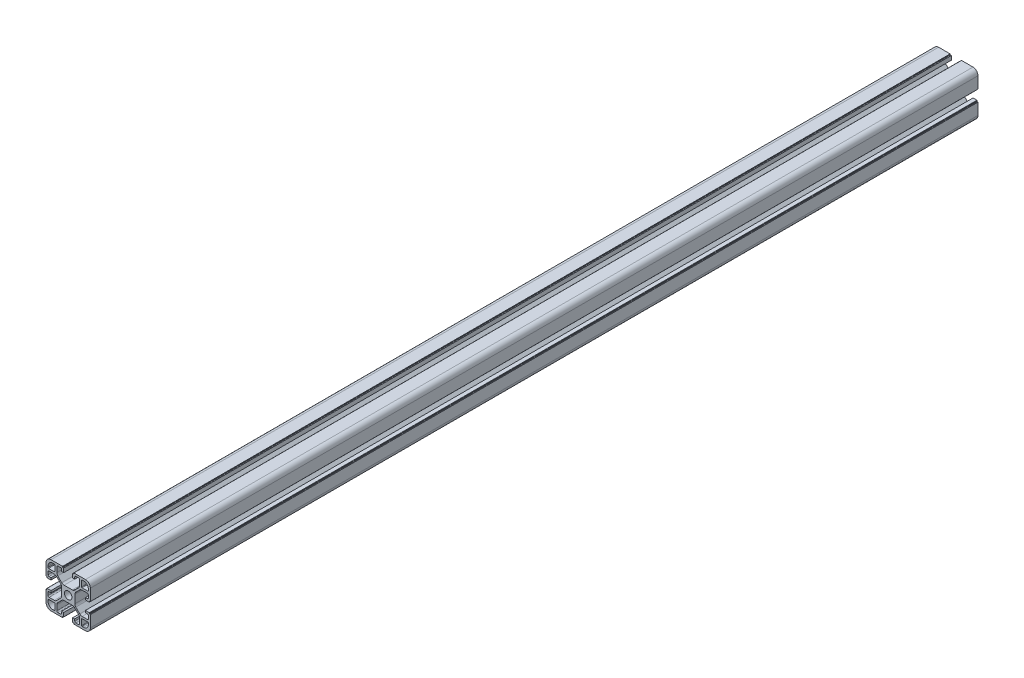
from build123d import *

# Parameters (mm, degrees)
BOSS_EXTRUDE1_DEPTH = 800


with BuildPart() as part:
    # Sketch2 → Boss-Extrude1 (new body)
    with BuildSketch(Plane.XY):
        with BuildLine():
            Line((84.170223908, 31.720417041), (84.170223908, 42.120417041))
            Line((84.170223908, 42.120417041), (83.570223908, 42.120417041))
            ThreePointArc((83.570223908, 42.120417041), (83.428802552, 42.178995685), (83.370223908, 42.320417041))
            Line((83.370223908, 42.320417041), (83.370223908, 42.920417041))
            ThreePointArc((83.370223908, 42.920417041), (83.311645264, 43.061838398), (83.170223908, 43.120417041))
            Line((83.170223908, 43.120417041), (79.670223908, 43.120417041))
            Line((79.670223908, 43.120417041), (79.670223908, 41.320417041))
            Line((79.670223908, 41.320417041), (81.370223908, 41.320417041))
            ThreePointArc((81.370223908, 41.320417041), (82.077330689, 41.027523823), (82.370223908, 40.320417041))
            Line((82.370223908, 40.320417041), (82.370223908, 37.970417041))
            ThreePointArc((82.370223908, 37.970417041), (82.077330689, 37.26331026), (81.370223908, 36.970417041))
            Line((81.370223908, 36.970417041), (76.723524767, 36.970417041))
            ThreePointArc((76.723524767, 36.970417041), (75.57547447, 37.198778444), (74.602204423, 37.849096698))
            Line((74.602204423, 37.849096698), (71.048903564, 41.402397557))
            ThreePointArc((71.048903564, 41.402397557), (70.39858531, 42.375667603), (70.170223908, 43.5237179))
            Line((70.170223908, 43.5237179), (70.170223908, 50.917116183))
            ThreePointArc((70.170223908, 50.917116183), (70.39858531, 52.06516648), (71.048903564, 53.038436526))
            Line((71.048903564, 53.038436526), (74.602204423, 56.591737385))
            ThreePointArc((74.602204423, 56.591737385), (75.57547447, 57.242055639), (76.723524767, 57.470417041))
            Line((76.723524767, 57.470417041), (81.370223908, 57.470417041))
            ThreePointArc((81.370223908, 57.470417041), (82.077330689, 57.177523823), (82.370223908, 56.470417041))
            Line((82.370223908, 56.470417041), (82.370223908, 54.120417041))
            ThreePointArc((82.370223908, 54.120417041), (82.077330689, 53.41331026), (81.370223908, 53.120417041))
            Line((81.370223908, 53.120417041), (79.670223908, 53.120417041))
            Line((79.670223908, 53.120417041), (79.670223908, 51.320417041))
            Line((79.670223908, 51.320417041), (83.170223908, 51.320417041))
            ThreePointArc((83.170223908, 51.320417041), (83.311645264, 51.378995685), (83.370223908, 51.520417041))
            Line((83.370223908, 51.520417041), (83.370223908, 52.120417041))
            ThreePointArc((83.370223908, 52.120417041), (83.428802552, 52.261838398), (83.570223908, 52.320417041))
            Line((83.570223908, 52.320417041), (84.170223908, 52.320417041))
            Line((84.170223908, 52.320417041), (84.170223908, 62.720417041))
            ThreePointArc((84.170223908, 62.720417041), (82.852204423, 65.902397557), (79.670223908, 67.220417041))
            Line((79.670223908, 67.220417041), (69.270223908, 67.220417041))
            Line((69.270223908, 67.220417041), (69.270223908, 66.420417041))
            Line((69.270223908, 66.420417041), (68.470223908, 66.420417041))
            ThreePointArc((68.470223908, 66.420417041), (68.328802552, 66.361838398), (68.270223908, 66.220417041))
            Line((68.270223908, 66.220417041), (68.270223908, 62.720417041))
            Line((68.270223908, 62.720417041), (70.070223908, 62.720417041))
            Line((70.070223908, 62.720417041), (70.070223908, 64.420417041))
            ThreePointArc((70.070223908, 64.420417041), (70.363117127, 65.127523823), (71.070223908, 65.420417041))
            Line((71.070223908, 65.420417041), (73.420223908, 65.420417041))
            ThreePointArc((73.420223908, 65.420417041), (74.127330689, 65.127523823), (74.420223908, 64.420417041))
            Line((74.420223908, 64.420417041), (74.420223908, 59.7737179))
            ThreePointArc((74.420223908, 59.7737179), (74.191862505, 58.625667603), (73.541544251, 57.652397557))
            Line((73.541544251, 57.652397557), (69.988243393, 54.099096698))
            ThreePointArc((69.988243393, 54.099096698), (69.014973346, 53.448778444), (67.866923049, 53.220417041))
            Line((67.866923049, 53.220417041), (60.473524767, 53.220417041))
            ThreePointArc((60.473524767, 53.220417041), (59.32547447, 53.448778444), (58.352204423, 54.099096698))
            Line((58.352204423, 54.099096698), (54.798903564, 57.652397557))
            ThreePointArc((54.798903564, 57.652397557), (54.14858531, 58.625667603), (53.920223908, 59.7737179))
            Line((53.920223908, 59.7737179), (53.920223908, 64.420417041))
            ThreePointArc((53.920223908, 64.420417041), (54.213117127, 65.127523823), (54.920223908, 65.420417041))
            Line((54.920223908, 65.420417041), (57.270223908, 65.420417041))
            ThreePointArc((57.270223908, 65.420417041), (57.977330689, 65.127523823), (58.270223908, 64.420417041))
            Line((58.270223908, 64.420417041), (58.270223908, 62.720417041))
            Line((58.270223908, 62.720417041), (60.070223908, 62.720417041))
            Line((60.070223908, 62.720417041), (60.070223908, 66.420417041))
            Line((60.070223908, 66.420417041), (59.270223908, 66.420417041))
            ThreePointArc((59.270223908, 66.420417041), (59.128802552, 66.478995685), (59.070223908, 66.620417041))
            Line((59.070223908, 66.620417041), (59.070223908, 67.220417041))
            Line((59.070223908, 67.220417041), (48.670223908, 67.220417041))
            ThreePointArc((48.670223908, 67.220417041), (45.488243393, 65.902397557), (44.170223908, 62.720417041))
            Line((44.170223908, 62.720417041), (44.170223908, 52.320417041))
            Line((44.170223908, 52.320417041), (44.770223908, 52.320417041))
            ThreePointArc((44.770223908, 52.320417041), (44.911645264, 52.261838398), (44.970223908, 52.120417041))
            Line((44.970223908, 52.120417041), (44.970223908, 51.520417041))
            ThreePointArc((44.970223908, 51.520417041), (45.028802552, 51.378995685), (45.170223908, 51.320417041))
            Line((45.170223908, 51.320417041), (48.670223908, 51.320417041))
            Line((48.670223908, 51.320417041), (48.670223908, 53.120417041))
            Line((48.670223908, 53.120417041), (46.970223908, 53.120417041))
            ThreePointArc((46.970223908, 53.120417041), (46.263117127, 53.41331026), (45.970223908, 54.120417041))
            Line((45.970223908, 54.120417041), (45.970223908, 56.470417041))
            ThreePointArc((45.970223908, 56.470417041), (46.263117127, 57.177523823), (46.970223908, 57.470417041))
            Line((46.970223908, 57.470417041), (51.616923049, 57.470417041))
            ThreePointArc((51.616923049, 57.470417041), (52.764973346, 57.242055639), (53.738243393, 56.591737385))
            Line((53.738243393, 56.591737385), (57.291544251, 53.038436526))
            ThreePointArc((57.291544251, 53.038436526), (57.941862505, 52.06516648), (58.170223908, 50.917116183))
            Line((58.170223908, 50.917116183), (58.170223908, 43.5237179))
            ThreePointArc((58.170223908, 43.5237179), (57.941862505, 42.375667603), (57.291544251, 41.402397557))
            Line((57.291544251, 41.402397557), (53.738243393, 37.849096698))
            ThreePointArc((53.738243393, 37.849096698), (52.764973346, 37.198778444), (51.616923049, 36.970417041))
            Line((51.616923049, 36.970417041), (46.970223908, 36.970417041))
            ThreePointArc((46.970223908, 36.970417041), (46.263117127, 37.26331026), (45.970223908, 37.970417041))
            Line((45.970223908, 37.970417041), (45.970223908, 40.320417041))
            ThreePointArc((45.970223908, 40.320417041), (46.263117127, 41.027523823), (46.970223908, 41.320417041))
            Line((46.970223908, 41.320417041), (48.670223908, 41.320417041))
            Line((48.670223908, 41.320417041), (48.670223908, 43.120417041))
            Line((48.670223908, 43.120417041), (45.170223908, 43.120417041))
            ThreePointArc((45.170223908, 43.120417041), (45.028802552, 43.061838398), (44.970223908, 42.920417041))
            Line((44.970223908, 42.920417041), (44.970223908, 42.320417041))
            ThreePointArc((44.970223908, 42.320417041), (44.911645264, 42.178995685), (44.770223908, 42.120417041))
            Line((44.770223908, 42.120417041), (44.170223908, 42.120417041))
            Line((44.170223908, 42.120417041), (44.170223908, 31.720417041))
            ThreePointArc((44.170223908, 31.720417041), (45.488243393, 28.538436526), (48.670223908, 27.220417041))
            Line((48.670223908, 27.220417041), (59.070223908, 27.220417041))
            Line((59.070223908, 27.220417041), (59.070223908, 27.820417041))
            ThreePointArc((59.070223908, 27.820417041), (59.128802552, 27.961838398), (59.270223908, 28.020417041))
            Line((59.270223908, 28.020417041), (59.870223908, 28.020417041))
            ThreePointArc((59.870223908, 28.020417041), (60.011645264, 28.078995685), (60.070223908, 28.220417041))
            Line((60.070223908, 28.220417041), (60.070223908, 31.720417041))
            Line((60.070223908, 31.720417041), (58.270223908, 31.720417041))
            Line((58.270223908, 31.720417041), (58.270223908, 30.020417041))
            ThreePointArc((58.270223908, 30.020417041), (57.977330689, 29.31331026), (57.270223908, 29.020417041))
            Line((57.270223908, 29.020417041), (54.920223908, 29.020417041))
            ThreePointArc((54.920223908, 29.020417041), (54.213117127, 29.31331026), (53.920223908, 30.020417041))
            Line((53.920223908, 30.020417041), (53.920223908, 34.667116183))
            ThreePointArc((53.920223908, 34.667116183), (54.14858531, 35.81516648), (54.798903564, 36.788436526))
            Line((54.798903564, 36.788436526), (58.352204423, 40.341737385))
            ThreePointArc((58.352204423, 40.341737385), (59.32547447, 40.992055639), (60.473524767, 41.220417041))
            Line((60.473524767, 41.220417041), (67.866923049, 41.220417041))
            ThreePointArc((67.866923049, 41.220417041), (69.014973346, 40.992055639), (69.988243393, 40.341737385))
            Line((69.988243393, 40.341737385), (73.541544251, 36.788436526))
            ThreePointArc((73.541544251, 36.788436526), (74.191862505, 35.81516648), (74.420223908, 34.667116183))
            Line((74.420223908, 34.667116183), (74.420223908, 30.020417041))
            ThreePointArc((74.420223908, 30.020417041), (74.127330689, 29.31331026), (73.420223908, 29.020417041))
            Line((73.420223908, 29.020417041), (71.070223908, 29.020417041))
            ThreePointArc((71.070223908, 29.020417041), (70.363117127, 29.31331026), (70.070223908, 30.020417041))
            Line((70.070223908, 30.020417041), (70.070223908, 31.720417041))
            Line((70.070223908, 31.720417041), (68.270223908, 31.720417041))
            Line((68.270223908, 31.720417041), (68.270223908, 28.220417041))
            ThreePointArc((68.270223908, 28.220417041), (68.328802552, 28.078995685), (68.470223908, 28.020417041))
            Line((68.470223908, 28.020417041), (69.070223908, 28.020417041))
            ThreePointArc((69.070223908, 28.020417041), (69.211645264, 27.961838398), (69.270223908, 27.820417041))
            Line((69.270223908, 27.820417041), (69.270223908, 27.220417041))
            Line((69.270223908, 27.220417041), (79.670223908, 27.220417041))
            ThreePointArc((79.670223908, 27.220417041), (82.852204423, 28.538436526), (84.170223908, 31.720417041))
        make_face()
        with BuildLine():
            Line((82.370223908, 34.670417041), (82.370223908, 33.520417041))
            ThreePointArc((82.370223908, 33.520417041), (81.052204423, 30.338436526), (77.870223908, 29.020417041))
            Line((77.870223908, 29.020417041), (76.720223908, 29.020417041))
            ThreePointArc((76.720223908, 29.020417041), (76.366670517, 29.166863651), (76.220223908, 29.520417041))
            Line((76.220223908, 29.520417041), (76.220223908, 34.670417041))
            ThreePointArc((76.220223908, 34.670417041), (76.366670517, 35.023970432), (76.720223908, 35.170417041))
            Line((76.720223908, 35.170417041), (81.870223908, 35.170417041))
            ThreePointArc((81.870223908, 35.170417041), (82.223777298, 35.023970432), (82.370223908, 34.670417041))
        make_face(mode=Mode.SUBTRACT)
        with BuildLine():
            Line((51.620223908, 29.020417041), (50.470223908, 29.020417041))
            ThreePointArc((50.470223908, 29.020417041), (47.288243393, 30.338436526), (45.970223908, 33.520417041))
            Line((45.970223908, 33.520417041), (45.970223908, 34.670417041))
            ThreePointArc((45.970223908, 34.670417041), (46.116670517, 35.023970432), (46.470223908, 35.170417041))
            Line((46.470223908, 35.170417041), (51.620223908, 35.170417041))
            ThreePointArc((51.620223908, 35.170417041), (51.973777298, 35.023970432), (52.120223908, 34.670417041))
            Line((52.120223908, 34.670417041), (52.120223908, 29.520417041))
            ThreePointArc((52.120223908, 29.520417041), (51.973777298, 29.166863651), (51.620223908, 29.020417041))
        make_face(mode=Mode.SUBTRACT)
        with BuildLine():
            Line((45.970223908, 59.770417041), (45.970223908, 60.920417041))
            ThreePointArc((45.970223908, 60.920417041), (47.288243393, 64.102397557), (50.470223908, 65.420417041))
            Line((50.470223908, 65.420417041), (51.620223908, 65.420417041))
            ThreePointArc((51.620223908, 65.420417041), (51.973777298, 65.273970432), (52.120223908, 64.920417041))
            Line((52.120223908, 64.920417041), (52.120223908, 59.770417041))
            ThreePointArc((52.120223908, 59.770417041), (51.973777298, 59.416863651), (51.620223908, 59.270417041))
            Line((51.620223908, 59.270417041), (46.470223908, 59.270417041))
            ThreePointArc((46.470223908, 59.270417041), (46.116670517, 59.416863651), (45.970223908, 59.770417041))
        make_face(mode=Mode.SUBTRACT)
        with BuildLine():
            Line((76.720223908, 65.420417041), (77.870223908, 65.420417041))
            ThreePointArc((77.870223908, 65.420417041), (81.052204423, 64.102397557), (82.370223908, 60.920417041))
            Line((82.370223908, 60.920417041), (82.370223908, 59.770417041))
            ThreePointArc((82.370223908, 59.770417041), (82.223777298, 59.416863651), (81.870223908, 59.270417041))
            Line((81.870223908, 59.270417041), (76.720223908, 59.270417041))
            ThreePointArc((76.720223908, 59.270417041), (76.366670517, 59.416863651), (76.220223908, 59.770417041))
            Line((76.220223908, 59.770417041), (76.220223908, 64.920417041))
            ThreePointArc((76.220223908, 64.920417041), (76.366670517, 65.273970432), (76.720223908, 65.420417041))
        make_face(mode=Mode.SUBTRACT)
        with BuildLine():
            ThreePointArc((60.770223908, 47.220417041), (64.170223908, 43.820417041), (67.570223908, 47.220417041))
            ThreePointArc((67.570223908, 47.220417041), (64.170223908, 50.620417041), (60.770223908, 47.220417041))
        make_face(mode=Mode.SUBTRACT)
    extrude(amount=BOSS_EXTRUDE1_DEPTH)


solid = part.part
